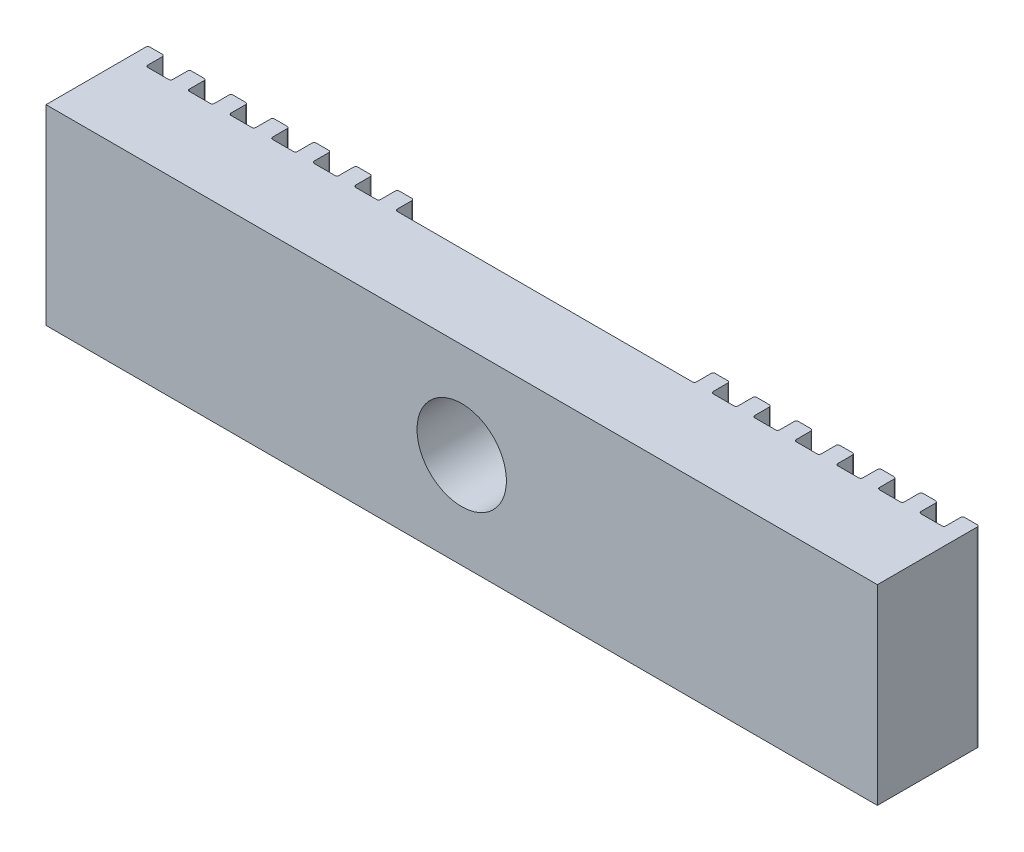
from build123d import *

# Parameters (mm, degrees)
RESSALTO_EXTRUS_O2_DEPTH = 9.2
ESBO_O5_R                = 2.15
CORTE_EXTRUS_O2_DEPTH    = 9.2
CHANFRO2_SIZE            = 0.3


with BuildPart() as part:
    # Esboço4 → Ressalto-extrusão2 (new body)
    with BuildSketch(Plane(origin=(0, 0, 0), x_dir=(1, 0, 0), z_dir=(0, 1, 0))):
        with BuildLine():
            Line((-19.2, 2.35), (-19.2, 1.65))
            ThreePointArc((-19.2, 1.65), (-19.170710678, 1.579289322), (-19.1, 1.55))
            Line((-19.1, 1.55), (-18.1, 1.55))
            ThreePointArc((-18.1, 1.55), (-18.029289322, 1.579289322), (-18, 1.65))
            Line((-18, 1.65), (-18, 2.35))
            ThreePointArc((-18, 2.35), (-17.970710678, 2.420710678), (-17.9, 2.45))
            Line((-17.9, 2.45), (-17.3, 2.45))
            ThreePointArc((-17.3, 2.45), (-17.229289322, 2.420710678), (-17.2, 2.35))
            Line((-17.2, 2.35), (-17.2, 1.65))
            ThreePointArc((-17.2, 1.65), (-17.170710678, 1.579289322), (-17.1, 1.55))
            Line((-17.1, 1.55), (-16.1, 1.55))
            ThreePointArc((-16.1, 1.55), (-16.029289322, 1.579289322), (-16, 1.65))
            Line((-16, 1.65), (-16, 2.35))
            ThreePointArc((-16, 2.35), (-15.970710678, 2.420710678), (-15.9, 2.45))
            Line((-15.9, 2.45), (-15.3, 2.45))
            ThreePointArc((-15.3, 2.45), (-15.229289322, 2.420710678), (-15.2, 2.35))
            Line((-15.2, 2.35), (-15.2, 1.65))
            ThreePointArc((-15.2, 1.65), (-15.170710678, 1.579289322), (-15.1, 1.55))
            Line((-15.1, 1.55), (-14.1, 1.55))
            ThreePointArc((-14.1, 1.55), (-14.029289322, 1.579289322), (-14, 1.65))
            Line((-14, 1.65), (-14, 2.35))
            ThreePointArc((-14, 2.35), (-13.970710678, 2.420710678), (-13.9, 2.45))
            Line((-13.9, 2.45), (-13.3, 2.45))
            ThreePointArc((-13.3, 2.45), (-13.229289322, 2.420710678), (-13.2, 2.35))
            Line((-13.2, 2.35), (-13.2, 1.65))
            ThreePointArc((-13.2, 1.65), (-13.170710678, 1.579289322), (-13.1, 1.55))
            Line((-13.1, 1.55), (-12.1, 1.55))
            ThreePointArc((-12.1, 1.55), (-12.029289322, 1.579289322), (-12, 1.65))
            Line((-12, 1.65), (-12, 2.35))
            ThreePointArc((-12, 2.35), (-11.970710678, 2.420710678), (-11.9, 2.45))
            Line((-11.9, 2.45), (-11.3, 2.45))
            ThreePointArc((-11.3, 2.45), (-11.229289322, 2.420710678), (-11.2, 2.35))
            Line((-11.2, 2.35), (-11.2, 1.65))
            ThreePointArc((-11.2, 1.65), (-11.170710678, 1.579289322), (-11.1, 1.55))
            Line((-11.1, 1.55), (-10.1, 1.55))
            ThreePointArc((-10.1, 1.55), (-10.029289322, 1.579289322), (-10, 1.65))
            Line((-10, 1.65), (-10, 2.35))
            ThreePointArc((-10, 2.35), (-9.970710678, 2.420710678), (-9.9, 2.45))
            Line((-9.9, 2.45), (-9.3, 2.45))
            ThreePointArc((-9.3, 2.45), (-9.229289322, 2.420710678), (-9.2, 2.35))
            Line((-9.2, 2.35), (-9.2, 1.65))
            ThreePointArc((-9.2, 1.65), (-9.170710678, 1.579289322), (-9.1, 1.55))
            Line((-9.1, 1.55), (-8.1, 1.55))
            ThreePointArc((-8.1, 1.55), (-8.029289322, 1.579289322), (-8, 1.65))
            Line((-8, 1.65), (-8, 2.35))
            ThreePointArc((-8, 2.35), (-7.970710678, 2.420710678), (-7.9, 2.45))
            Line((-7.9, 2.45), (-7.3, 2.45))
            ThreePointArc((-7.3, 2.45), (-7.229289322, 2.420710678), (-7.2, 2.35))
            Line((-7.2, 2.35), (-7.2, 1.65))
            ThreePointArc((-7.2, 1.65), (-7.170710678, 1.579289322), (-7.1, 1.55))
            Line((-7.1, 1.55), (7.1, 1.55))
            ThreePointArc((7.1, 1.55), (7.170710678, 1.579289322), (7.2, 1.65))
            Line((7.2, 1.65), (7.2, 2.35))
            ThreePointArc((7.2, 2.35), (7.229289322, 2.420710678), (7.3, 2.45))
            Line((7.3, 2.45), (7.9, 2.45))
            ThreePointArc((7.9, 2.45), (7.970710678, 2.420710678), (8, 2.35))
            Line((8, 2.35), (8, 1.65))
            ThreePointArc((8, 1.65), (8.029289322, 1.579289322), (8.1, 1.55))
            Line((8.1, 1.55), (9.1, 1.55))
            ThreePointArc((9.1, 1.55), (9.170710678, 1.579289322), (9.2, 1.65))
            Line((9.2, 1.65), (9.2, 2.35))
            ThreePointArc((9.2, 2.35), (9.229289322, 2.420710678), (9.3, 2.45))
            Line((9.3, 2.45), (9.9, 2.45))
            ThreePointArc((9.9, 2.45), (9.970710678, 2.420710678), (10, 2.35))
            Line((10, 2.35), (10, 1.65))
            ThreePointArc((10, 1.65), (10.029289322, 1.579289322), (10.1, 1.55))
            Line((10.1, 1.55), (11.1, 1.55))
            ThreePointArc((11.1, 1.55), (11.170710678, 1.579289322), (11.2, 1.65))
            Line((11.2, 1.65), (11.2, 2.35))
            ThreePointArc((11.2, 2.35), (11.229289322, 2.420710678), (11.3, 2.45))
            Line((11.3, 2.45), (11.9, 2.45))
            ThreePointArc((11.9, 2.45), (11.970710678, 2.420710678), (12, 2.35))
            Line((12, 2.35), (12, 1.65))
            ThreePointArc((12, 1.65), (12.029289322, 1.579289322), (12.1, 1.55))
            Line((12.1, 1.55), (13.1, 1.55))
            ThreePointArc((13.1, 1.55), (13.170710678, 1.579289322), (13.2, 1.65))
            Line((13.2, 1.65), (13.2, 2.35))
            ThreePointArc((13.2, 2.35), (13.229289322, 2.420710678), (13.3, 2.45))
            Line((13.3, 2.45), (13.9, 2.45))
            ThreePointArc((13.9, 2.45), (13.970710678, 2.420710678), (14, 2.35))
            Line((14, 2.35), (14, 1.65))
            ThreePointArc((14, 1.65), (14.029289322, 1.579289322), (14.1, 1.55))
            Line((14.1, 1.55), (15.1, 1.55))
            ThreePointArc((15.1, 1.55), (15.170710678, 1.579289322), (15.2, 1.65))
            Line((15.2, 1.65), (15.2, 2.35))
            ThreePointArc((15.2, 2.35), (15.229289322, 2.420710678), (15.3, 2.45))
            Line((15.3, 2.45), (15.9, 2.45))
            ThreePointArc((15.9, 2.45), (15.970710678, 2.420710678), (16, 2.35))
            Line((16, 2.35), (16, 1.65))
            ThreePointArc((16, 1.65), (16.029289322, 1.579289322), (16.1, 1.55))
            Line((16.1, 1.55), (17.1, 1.55))
            ThreePointArc((17.1, 1.55), (17.170710678, 1.579289322), (17.2, 1.65))
            Line((17.2, 1.65), (17.2, 2.35))
            ThreePointArc((17.2, 2.35), (17.229289322, 2.420710678), (17.3, 2.45))
            Line((17.3, 2.45), (17.9, 2.45))
            ThreePointArc((17.9, 2.45), (17.970710678, 2.420710678), (18, 2.35))
            Line((18, 2.35), (18, 1.65))
            ThreePointArc((18, 1.65), (18.029289322, 1.579289322), (18.1, 1.55))
            Line((18.1, 1.55), (19.1, 1.55))
            ThreePointArc((19.1, 1.55), (19.170710678, 1.579289322), (19.2, 1.65))
            Line((19.2, 1.65), (19.2, 2.35))
            ThreePointArc((19.2, 2.35), (19.229289322, 2.420710678), (19.3, 2.45))
            Line((19.3, 2.45), (19.9, 2.45))
            ThreePointArc((19.9, 2.45), (19.970710678, 2.420710678), (20, 2.35))
            Line((20, 2.35), (20, -2.45))
            Line((20, -2.45), (-20, -2.45))
            Line((-20, -2.45), (-20, 2.35))
            ThreePointArc((-20, 2.35), (-19.970710678, 2.420710678), (-19.9, 2.45))
            Line((-19.9, 2.45), (-19.3, 2.45))
            ThreePointArc((-19.3, 2.45), (-19.229289322, 2.420710678), (-19.2, 2.35))
        make_face()
    extrude(amount=RESSALTO_EXTRUS_O2_DEPTH)

    # Esboço5 → Corte-extrusão2 (cut)
    with BuildSketch(Plane(origin=(0, 0, -1.55), x_dir=(-1, 0, 0), z_dir=(0, 0, -1))):
        with Locations((0, 4.6)):
            Circle(ESBO_O5_R)
    extrude(amount=-CORTE_EXTRUS_O2_DEPTH, mode=Mode.SUBTRACT)

    # Chanfro2
    chanfro2_edges = [part.edges().sort_by_distance(p)[0] for p in [
        (2.15, 4.6, -1.55),
    ]]
    chamfer(chanfro2_edges, length=CHANFRO2_SIZE)


solid = part.part
